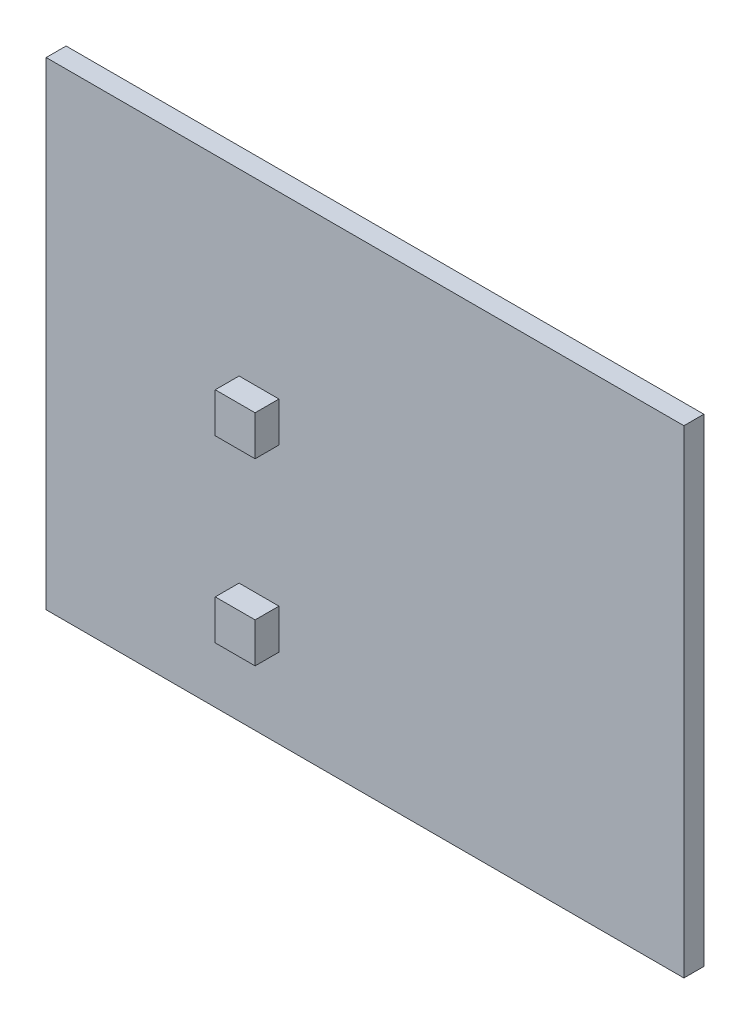
from build123d import *

# Parameters (mm, degrees)
SKETCH1_W           = 80
SKETCH1_H           = 60
BOSS_EXTRUDE1_DEPTH = 2.5
SKETCH2_W           = 5
SKETCH2_H           = 5
BOSS_EXTRUDE2_DEPTH = 2.99


with BuildPart() as part:
    # Sketch1 → Boss-Extrude1 (new body)
    with BuildSketch(Plane.XY):
        Rectangle(SKETCH1_W, SKETCH1_H)
    extrude(amount=BOSS_EXTRUDE1_DEPTH)

    # Sketch2 → Boss-Extrude2 (add)
    with BuildSketch(Plane.XY.offset(2.5)):
        with Locations((-13.3, -17.5)):
            Rectangle(SKETCH2_W, SKETCH2_H)
        with Locations((-13.3, 5)):
            Rectangle(SKETCH2_W, SKETCH2_H)
    extrude(amount=BOSS_EXTRUDE2_DEPTH)


solid = part.part
